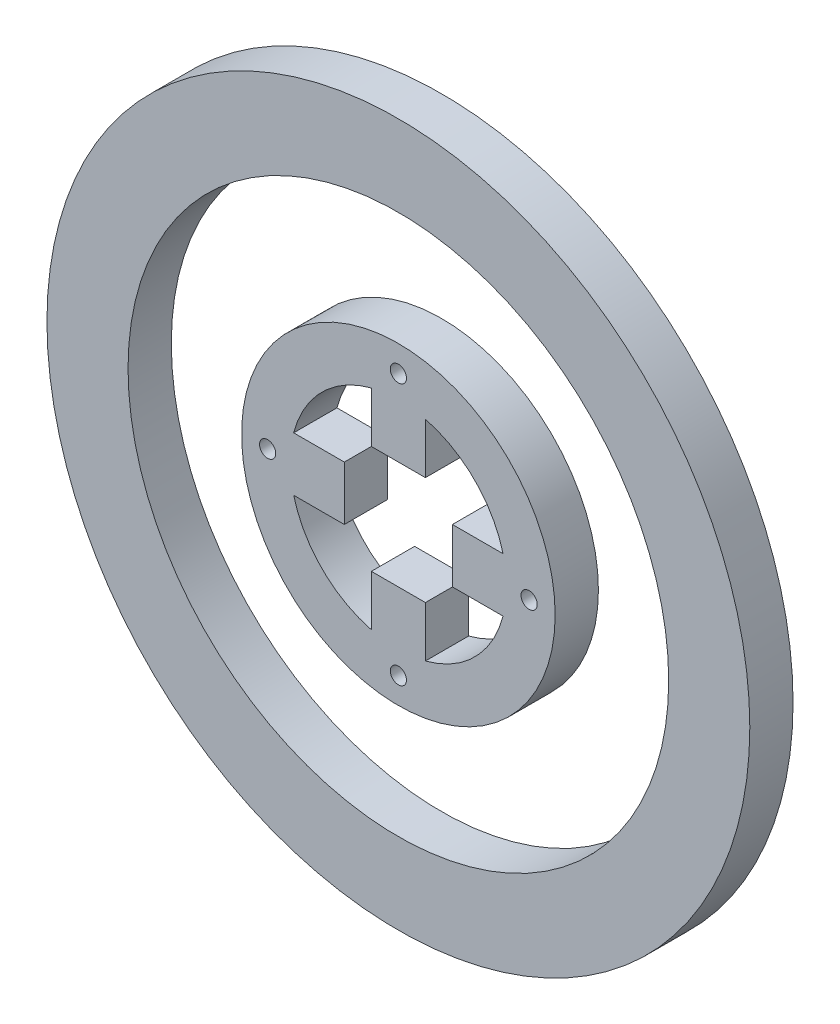
from build123d import *

# Parameters (mm, degrees)
SKETCH1_R                 = 65
SKETCH1_R_2               = 50
OUTER_RING_DEPTH          = 8
SKETCH6_R                 = 29
SKETCH6_R_2               = 20
INNER_RING_DEPTH          = 8
MOTOR_CONNECTOR_CUT_DEPTH = 8
SKETCH8_R                 = 1.5
M3_HOLES_DEPTH            = 38
M3_HOLES_DEPTH_BACK       = 14


with BuildPart() as part:
    # Sketch1 → Outer Ring (new body)
    with BuildSketch(Plane.XY):
        Circle(SKETCH1_R)
        Circle(SKETCH1_R_2, mode=Mode.SUBTRACT)
    extrude(amount=OUTER_RING_DEPTH)


with BuildPart() as body_2:
    # Sketch6 → Inner Ring (new body)
    with BuildSketch(Plane.XY.offset(8)):
        Circle(SKETCH6_R)
        Circle(SKETCH6_R_2, mode=Mode.SUBTRACT)
    extrude(amount=-INNER_RING_DEPTH)

    # Sketch7 → Motor Connector Cut (add)
    with BuildSketch(Plane.XY.offset(8)):
        with BuildLine():
            ThreePointArc((20, 0), (19.840593925, 2.52008585), (19.364916731, 5))
            Line((19.364916731, 5), (9.999996731, 5))
            Line((9.999996731, 5), (9.999996731, -5))
            Line((9.999996731, -5), (19.364916731, -5))
            ThreePointArc((19.364916731, -5), (19.840593925, -2.52008585), (20, 0))
        make_face()
        with BuildLine():
            ThreePointArc((5, 19.364916731), (0, 20), (-5, 19.364916731))
            Line((-5, 19.364916731), (-5, 9.999996731))
            Line((-5, 9.999996731), (5, 9.999996731))
            Line((5, 9.999996731), (5, 19.364916731))
        make_face()
        with BuildLine():
            Line((-9.999996731, -5), (-9.999996731, 5))
            Line((-9.999996731, 5), (-19.364916731, 5))
            ThreePointArc((-19.364916731, 5), (-20, 0), (-19.364916731, -5))
            Line((-19.364916731, -5), (-9.999996731, -5))
        make_face()
        with BuildLine():
            Line((-5, -9.999996731), (-5, -19.364916731))
            ThreePointArc((-5, -19.364916731), (0, -20), (5, -19.364916731))
            Line((5, -19.364916731), (5, -9.999996731))
            Line((5, -9.999996731), (-5, -9.999996731))
        make_face()
    extrude(amount=-MOTOR_CONNECTOR_CUT_DEPTH)

    # Sketch8 → M3 Holes (cut, two sides)
    with BuildSketch(Plane.XY.offset(8)) as m3_holes_sk:
        with Locations((0, 24.182458366)):
            Circle(SKETCH8_R)
        with Locations((24.182458366, 0)):
            Circle(SKETCH8_R)
        with Locations((0, -24.182458366)):
            Circle(SKETCH8_R)
        with Locations((-24.182458366, 0)):
            Circle(SKETCH8_R)
    extrude(amount=M3_HOLES_DEPTH, mode=Mode.SUBTRACT)
    extrude(m3_holes_sk.sketch, amount=-M3_HOLES_DEPTH_BACK, mode=Mode.SUBTRACT)


solid = Compound([part.part, body_2.part])
